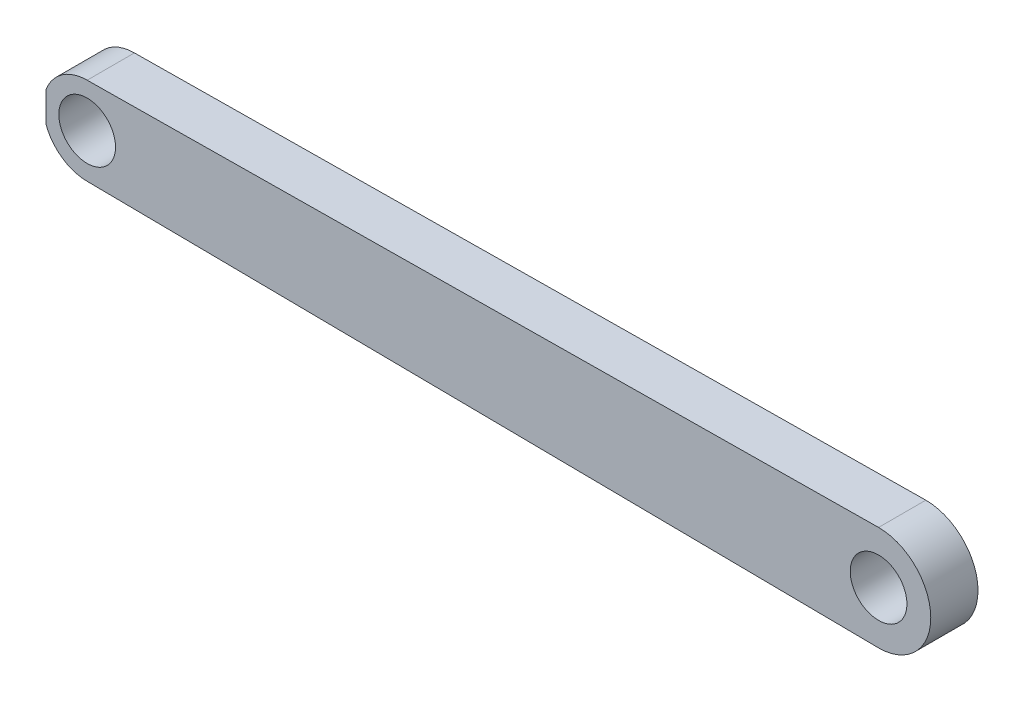
from build123d import *

# Parameters (mm, degrees)
SZKIC1_R                    = 4.635188213
SZKIC1_R_2                  = 3.000000079
SZKIC1_R_3                  = 5.522620658
DODANIE_WYCI_GNI_CIE1_DEPTH = 5
SZKIC2_W                    = 1.618528634
SZKIC2_H                    = 7.505645785
SZKIC2_W_2                  = 0.651830256
SZKIC2_H_2                  = 5.051684483
WYTNIJ_WYCI_GNI_CIE3_DEPTH  = 6


with BuildPart() as part:
    # Szkic1 → Dodanie-wyciągnięcie1 (new body)
    with BuildSketch(Plane.XY):
        with BuildLine():
            Line((0, -4.635188213), (83.645408354, -5.521381009))
            ThreePointArc((83.645408354, -5.521381009), (78.239794892, 0), (83.645408354, 5.521381009))
            Line((83.645408354, 5.521381009), (0, 4.635188213))
            ThreePointArc((0, 4.635188213), (3.277573017, 3.277573017), (4.635188213, 0))
            ThreePointArc((4.635188213, 0), (3.277573017, -3.277573017), (0, -4.635188213))
        make_face()
        Circle(SZKIC1_R)
        Circle(SZKIC1_R_2, mode=Mode.SUBTRACT)
        with BuildLine():
            ThreePointArc((0, 4.635188213), (-4.635188213, 0), (0, -4.635188213))
            ThreePointArc((0, -4.635188213), (3.277573017, -3.277573017), (4.635188213, 0))
            ThreePointArc((4.635188213, 0), (3.277573017, 3.277573017), (0, 4.635188213))
        make_face()
        Circle(SZKIC1_R_2, mode=Mode.SUBTRACT)
        with BuildLine():
            ThreePointArc((83.645408354, -5.521381009), (83.703908669, -5.522310737), (83.76241555, -5.522620658))
            Line((83.76241555, -5.522620658), (83.645408354, -5.521381009))
        make_face()
        with Locations((83.76241555, 0)):
            Circle(SZKIC1_R_3)
        with Locations((83.76241555, 0)):
            Circle(SZKIC1_R_2, mode=Mode.SUBTRACT)
        with BuildLine():
            ThreePointArc((83.76241555, 5.522620658), (83.703908669, 5.522310737), (83.645408354, 5.521381009))
            Line((83.645408354, 5.521381009), (83.76241555, 5.522620658))
        make_face()
    extrude(amount=DODANIE_WYCI_GNI_CIE1_DEPTH)

    # Szkic2 → Wytnij-wyciągnięcie3 (cut, through all)
    with BuildSketch(Plane.XY):
        with Locations((193.638606269, 0.381285041)):
            Rectangle(SZKIC2_W, SZKIC2_H)
        with Locations((-4.682734605, -0.038745932)):
            Rectangle(SZKIC2_W_2, SZKIC2_H_2)
    extrude(amount=WYTNIJ_WYCI_GNI_CIE3_DEPTH, mode=Mode.SUBTRACT)


solid = part.part
